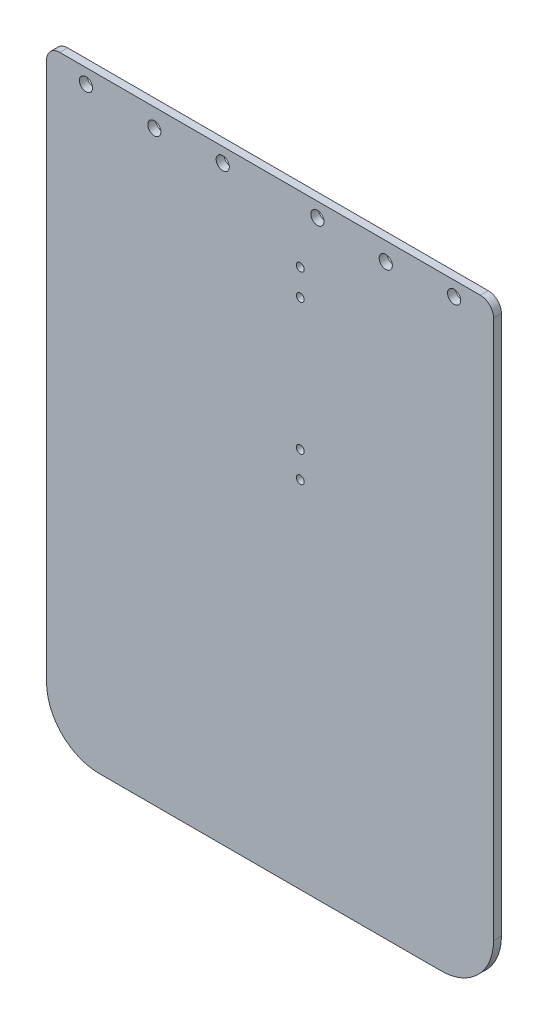
from build123d import *

# Parameters (mm, degrees)
SKETCH_1_W          = 170
SKETCH_1_H          = 200
EXTRUDE_1_DEPTH     = 3
SKETCH_4_W          = 170
SKETCH_4_H          = 30
EXTRUDE_2_DEPTH     = 3
FILLET_1_R          = 20
FILLET_2_R          = 5
SKETCH_6_R          = 1.5
CUT_EXTRUDE_3_DEPTH = 4
SKETCH_7_R          = 2.5
CUT_EXTRUDE_4_DEPTH = 10


with BuildPart() as part:
    # 草图1 → 凸台-拉伸1 (new body)
    with BuildSketch(Plane.XY):
        Rectangle(SKETCH_1_W, SKETCH_1_H)
    extrude(amount=EXTRUDE_1_DEPTH)

    # 草图4 → 凸台-拉伸2 (add)
    with BuildSketch(Plane(origin=(0, 0, 0), x_dir=(-1, 0, 0), z_dir=(0, 0, -1))):
        with Locations((0, -115)):
            Rectangle(SKETCH_4_W, SKETCH_4_H)
    extrude(amount=-EXTRUDE_2_DEPTH)

    # 圆角1
    fillet_1_edges = [part.edges().sort_by_distance(p)[0] for p in [
        (-85, -130, 1.5),
        (85, -130, 1.5),
    ]]
    fillet(fillet_1_edges, radius=FILLET_1_R)

    # 圆角2
    fillet_2_edges = [part.edges().sort_by_distance(p)[0] for p in [
        (-85, 100, 1.5),
        (85, 100, 1.5),
    ]]
    fillet(fillet_2_edges, radius=FILLET_2_R)

    # 草图6 → 切除-拉伸3 (cut, through all)
    with BuildSketch(Plane.XY.offset(3)):
        with Locations((11.5, 5)):
            Circle(SKETCH_6_R)
        with Locations((11.5, 15)):
            Circle(SKETCH_6_R)
        with Locations((11.5, 65)):
            Circle(SKETCH_6_R)
        with Locations((11.5, 75)):
            Circle(SKETCH_6_R)
    extrude(amount=-CUT_EXTRUDE_3_DEPTH, mode=Mode.SUBTRACT)

    # 草图7 → 切除-拉伸4 (cut)
    with BuildSketch(Plane(origin=(0, 0, 0), x_dir=(-1, 0, 0), z_dir=(0, 0, -1))):
        with Locations((-18, 94.5)):
            Circle(SKETCH_7_R)
        with Locations((-70, 94.5)):
            Circle(SKETCH_7_R)
        with Locations((-44, 93)):
            Circle(SKETCH_7_R)
        with Locations((70, 94.5)):
            Circle(SKETCH_7_R)
        with Locations((44, 93)):
            Circle(SKETCH_7_R)
        with Locations((18, 94.5)):
            Circle(SKETCH_7_R)
    extrude(amount=-CUT_EXTRUDE_4_DEPTH, mode=Mode.SUBTRACT)


solid = part.part
